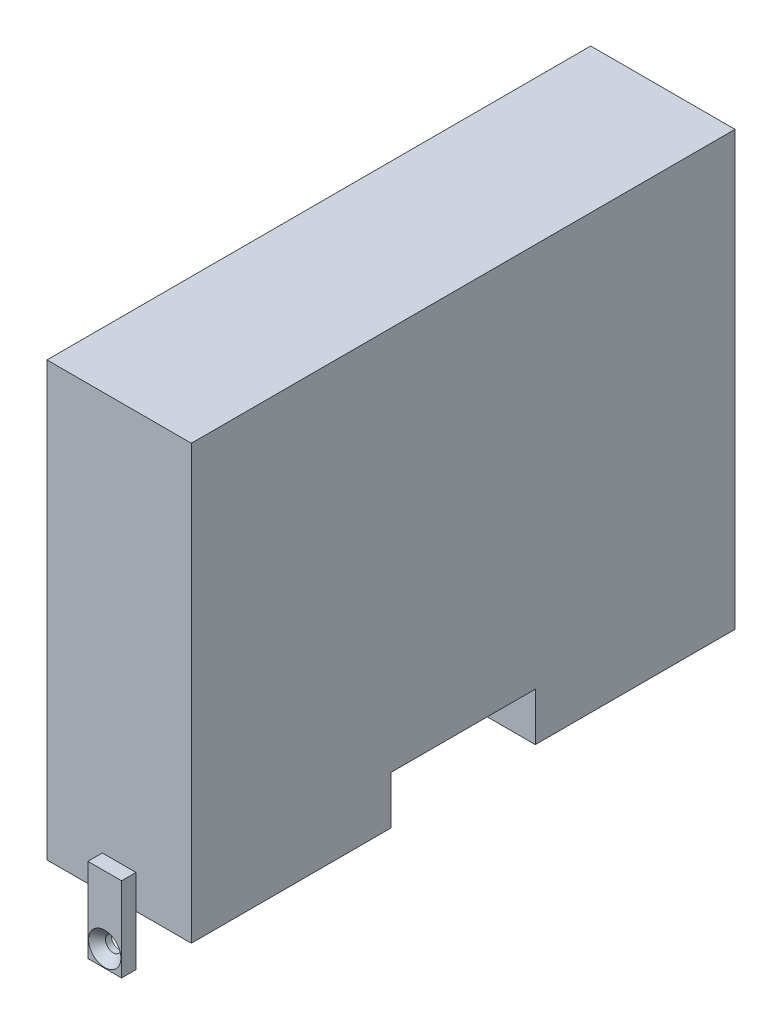
from build123d import *

# Parameters (mm, degrees)
SKETCH1_W                                            = 30
SKETCH1_H                                            = 113
BOSS_EXTRUDE1_DEPTH                                  = 90
SKETCH3_W                                            = 95
SKETCH3_H                                            = 45.23
CUT_EXTRUDE1_DEPTH                                   = 90
SKETCH4_W                                            = 30
SKETCH4_H                                            = 10
CUT_EXTRUDE2_DEPTH                                   = 10
F_5_0_5_DIAMETER_HOLE1_D                             = 5
F_5_0_5_DIAMETER_HOLE1_DEPTH                         = 6.497848452
F_5_0_5_DIAMETER_HOLE1_CSINK_D                       = 5.05
F_5_0_5_DIAMETER_HOLE1_CSINK_ANGLE                   = 90
F_5_0_5_DIAMETER_HOLE1_TIP                           = 1.502151548
SKETCH9_W                                            = 7
SKETCH9_H                                            = 17.5
BOSS_EXTRUDE2_DEPTH                                  = 3
CSK_FOR_M3_HEX_SOCKET_COUNTERSUNK_CAP_SC_D           = 3.2
CSK_FOR_M3_HEX_SOCKET_COUNTERSUNK_CAP_SC_DEPTH       = 7.23862301
CSK_FOR_M3_HEX_SOCKET_COUNTERSUNK_CAP_SC_CSINK_D     = 6.72
CSK_FOR_M3_HEX_SOCKET_COUNTERSUNK_CAP_SC_CSINK_ANGLE = 90
CSK_FOR_M3_HEX_SOCKET_COUNTERSUNK_CAP_SC_TIP         = 0.96137699
SKETCH14_W                                           = 7
SKETCH14_H                                           = 17.5
BOSS_EXTRUDE3_DEPTH                                  = 3
CSK_FOR_M3_HEX_SOCKET_COUNTERSUNK_CA_2_D             = 3.2
CSK_FOR_M3_HEX_SOCKET_COUNTERSUNK_CA_2_DEPTH         = 7.23862301
CSK_FOR_M3_HEX_SOCKET_COUNTERSUNK_CA_2_CSINK_D       = 6.72
CSK_FOR_M3_HEX_SOCKET_COUNTERSUNK_CA_2_CSINK_ANGLE   = 90
CSK_FOR_M3_HEX_SOCKET_COUNTERSUNK_CA_2_TIP           = 0.96137699


with BuildPart() as part:
    # Sketch1 → Boss-Extrude1 (new body)
    with BuildSketch(Plane(origin=(0, 0, 0), x_dir=(1, 0, 0), z_dir=(0, 1, 0))):
        Rectangle(SKETCH1_W, SKETCH1_H)
    extrude(amount=BOSS_EXTRUDE1_DEPTH)

    # Sketch3 → Cut-Extrude1 (cut)
    with BuildSketch(Plane(origin=(0, 0, 0), x_dir=(0, 0, -1), z_dir=(1, 0, 0))):
        with Locations((0, 62.385)):
            Rectangle(SKETCH3_W, SKETCH3_H)
    extrude(amount=-CUT_EXTRUDE1_DEPTH, mode=Mode.SUBTRACT)

    # Sketch4 → Cut-Extrude2 (cut)
    with BuildSketch(Plane(origin=(15, 0, 0), x_dir=(0, 0, -1), z_dir=(1, 0, 0))):
        with Locations((0, 5)):
            Rectangle(SKETCH4_W, SKETCH4_H)
    extrude(amount=-CUT_EXTRUDE2_DEPTH, mode=Mode.SUBTRACT)

    # Ø5.0 (5) Diameter Hole1
    with Locations(Plane(origin=(0, 39.77, 0), x_dir=(1, 0, 0), z_dir=(0, 1, 0))):
        with Locations((-8.5, 23.38), (-8.5, -18.62)):
            CounterSinkHole(F_5_0_5_DIAMETER_HOLE1_D / 2, F_5_0_5_DIAMETER_HOLE1_CSINK_D / 2, depth=F_5_0_5_DIAMETER_HOLE1_DEPTH, counter_sink_angle=F_5_0_5_DIAMETER_HOLE1_CSINK_ANGLE)
            with Locations((0, 0, -(F_5_0_5_DIAMETER_HOLE1_DEPTH + F_5_0_5_DIAMETER_HOLE1_TIP / 2))):  # 118° drill point
                Cone(0, F_5_0_5_DIAMETER_HOLE1_D / 2, F_5_0_5_DIAMETER_HOLE1_TIP, mode=Mode.SUBTRACT)

    # Sketch9 → Boss-Extrude2 (add)
    with BuildSketch(Plane(origin=(0, 0, -56.5), x_dir=(-1, 0, 0), z_dir=(0, 0, -1))):
        with Locations((0, -2)):
            Rectangle(SKETCH9_W, SKETCH9_H)
    extrude(amount=BOSS_EXTRUDE2_DEPTH)

    # CSK for M3 Hex Socket Countersunk Cap Sc
    with Locations(Plane(origin=(0, 0, -59.5), x_dir=(-1, 0, 0), z_dir=(0, 0, -1))):
        with Locations((0, -7.25)):
            CounterSinkHole(CSK_FOR_M3_HEX_SOCKET_COUNTERSUNK_CAP_SC_D / 2, CSK_FOR_M3_HEX_SOCKET_COUNTERSUNK_CAP_SC_CSINK_D / 2, depth=CSK_FOR_M3_HEX_SOCKET_COUNTERSUNK_CAP_SC_DEPTH, counter_sink_angle=CSK_FOR_M3_HEX_SOCKET_COUNTERSUNK_CAP_SC_CSINK_ANGLE)
            with Locations((0, 0, -(CSK_FOR_M3_HEX_SOCKET_COUNTERSUNK_CAP_SC_DEPTH + CSK_FOR_M3_HEX_SOCKET_COUNTERSUNK_CAP_SC_TIP / 2))):  # 118° drill point
                Cone(0, CSK_FOR_M3_HEX_SOCKET_COUNTERSUNK_CAP_SC_D / 2, CSK_FOR_M3_HEX_SOCKET_COUNTERSUNK_CAP_SC_TIP, mode=Mode.SUBTRACT)

    # Sketch14 → Boss-Extrude3 (add)
    with BuildSketch(Plane.XY.offset(56.5)):
        with Locations((0, -1.75)):
            Rectangle(SKETCH14_W, SKETCH14_H)
    extrude(amount=BOSS_EXTRUDE3_DEPTH)

    # CSK for M3 Hex Socket Countersunk Ca 2
    with Locations(Plane.XY.offset(59.5)):
        with Locations((0, -7)):
            CounterSinkHole(CSK_FOR_M3_HEX_SOCKET_COUNTERSUNK_CA_2_D / 2, CSK_FOR_M3_HEX_SOCKET_COUNTERSUNK_CA_2_CSINK_D / 2, depth=CSK_FOR_M3_HEX_SOCKET_COUNTERSUNK_CA_2_DEPTH, counter_sink_angle=CSK_FOR_M3_HEX_SOCKET_COUNTERSUNK_CA_2_CSINK_ANGLE)
            with Locations((0, 0, -(CSK_FOR_M3_HEX_SOCKET_COUNTERSUNK_CA_2_DEPTH + CSK_FOR_M3_HEX_SOCKET_COUNTERSUNK_CA_2_TIP / 2))):  # 118° drill point
                Cone(0, CSK_FOR_M3_HEX_SOCKET_COUNTERSUNK_CA_2_D / 2, CSK_FOR_M3_HEX_SOCKET_COUNTERSUNK_CA_2_TIP, mode=Mode.SUBTRACT)


solid = part.part
